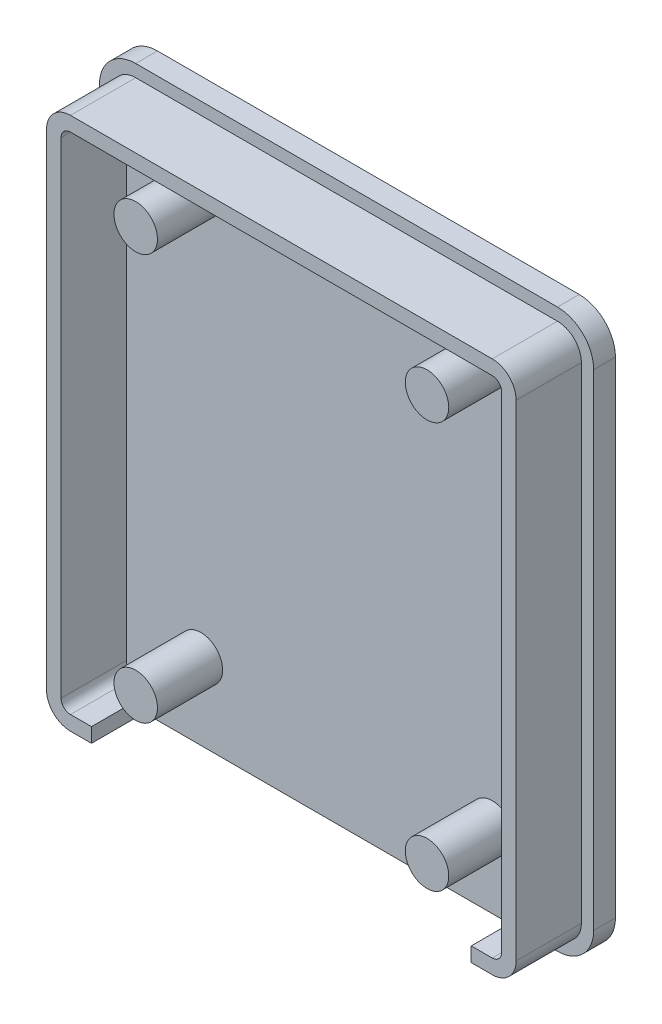
from build123d import *

# Parameters (mm, degrees)
BOSS_EXTRUDE1_DEPTH = 1.5
SKETCH1_3_R         = 1.5
BOSS_EXTRUDE2_DEPTH = 6


with BuildPart() as part:
    # Sketch1 → Boss-Extrude1 (new body)
    with BuildSketch(Plane.XY):
        with BuildLine():
            ThreePointArc((-17.05, -16.75), (-16.317766953, -18.517766953), (-14.55, -19.25))
            Line((-14.55, -19.25), (14.55, -19.25))
            ThreePointArc((14.55, -19.25), (16.317766953, -18.517766953), (17.05, -16.75))
            Line((17.05, -16.75), (17.05, 16.75))
            ThreePointArc((17.05, 16.75), (16.317766953, 18.517766953), (14.55, 19.25))
            Line((14.55, 19.25), (-14.55, 19.25))
            ThreePointArc((-14.55, 19.25), (-16.317766953, 18.517766953), (-17.05, 16.75))
            Line((-17.05, 16.75), (-17.05, -16.75))
        make_face()
    extrude(amount=BOSS_EXTRUDE1_DEPTH)

    # Sketch1_3 → Boss-Extrude2 (add)
    with BuildSketch(Plane.XY):
        with BuildLine():
            Line((-16.2, 16.75), (-16.2, -16.75))
            ThreePointArc((-16.2, -16.75), (-15.716726189, -17.916726189), (-14.55, -18.4))
            Line((-14.55, -18.4), (-13.10076635, -18.4))
            Line((-13.10076635, -18.4), (-13.10076635, -17.4))
            Line((-13.10076635, -17.4), (-14.55, -17.4))
            ThreePointArc((-14.55, -17.4), (-15.009619408, -17.209619408), (-15.2, -16.75))
            Line((-15.2, -16.75), (-15.2, 16.75))
            ThreePointArc((-15.2, 16.75), (-15.009619408, 17.209619408), (-14.55, 17.4))
            Line((-14.55, 17.4), (14.55, 17.4))
            ThreePointArc((14.55, 17.4), (15.009619408, 17.209619408), (15.2, 16.75))
            Line((15.2, 16.75), (15.2, -16.75))
            ThreePointArc((15.2, -16.75), (15.009619408, -17.209619408), (14.55, -17.4))
            Line((14.55, -17.4), (13.10076635, -17.4))
            Line((13.10076635, -17.4), (13.10076635, -18.4))
            Line((13.10076635, -18.4), (14.55, -18.4))
            ThreePointArc((14.55, -18.4), (15.716726189, -17.916726189), (16.2, -16.75))
            Line((16.2, -16.75), (16.2, 16.75))
            ThreePointArc((16.2, 16.75), (15.716726189, 17.916726189), (14.55, 18.4))
            Line((14.55, 18.4), (-14.55, 18.4))
            ThreePointArc((-14.55, 18.4), (-15.716726189, 17.916726189), (-16.2, 16.75))
        make_face()
        with Locations((-10.05, 14)):
            Circle(SKETCH1_3_R)
        with Locations((10.05, 14)):
            Circle(SKETCH1_3_R)
        with Locations((10.05, -14)):
            Circle(SKETCH1_3_R)
        with Locations((-10.05, -14)):
            Circle(SKETCH1_3_R)
    extrude(amount=BOSS_EXTRUDE2_DEPTH)


solid = part.part
